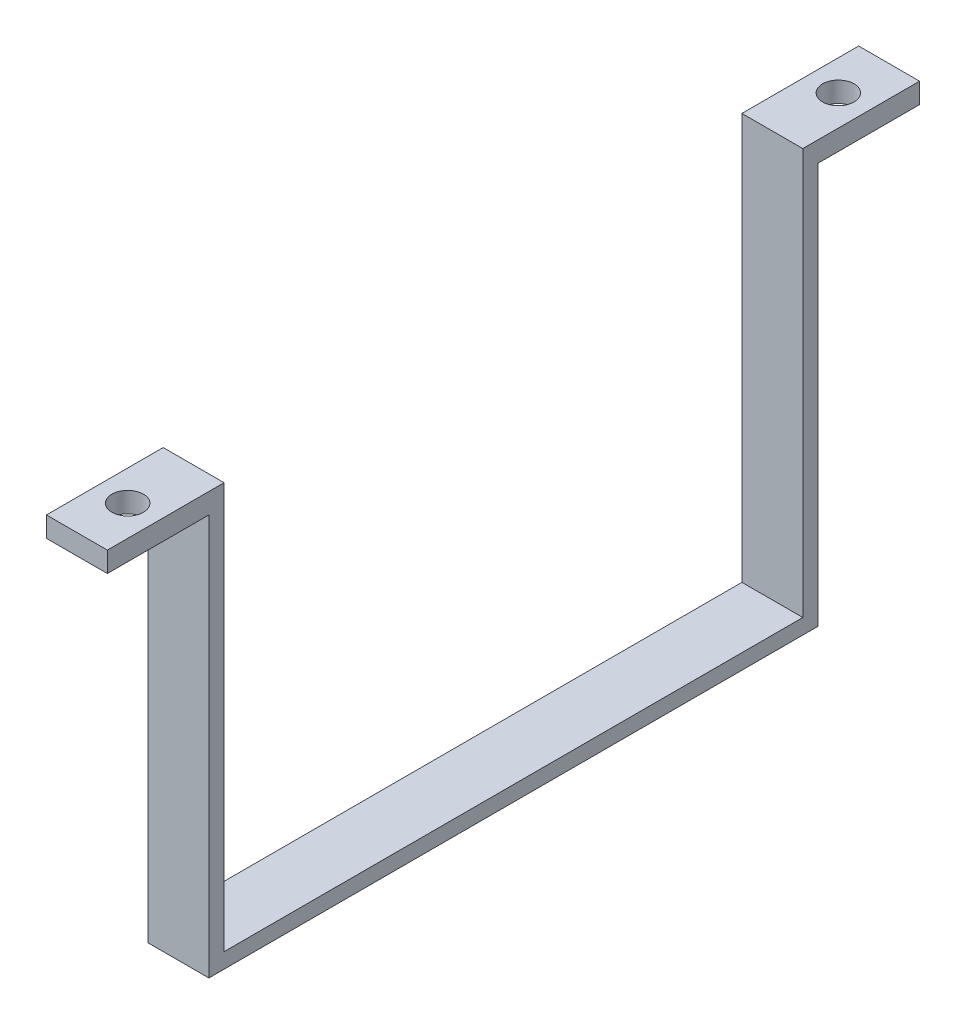
from build123d import *

# Parameters (mm, degrees)
SKETCH1_W           = 50
SKETCH1_H           = 60
SKETCH1_W_2         = 47
SKETCH1_H_2         = 57
BOSS_EXTRUDE6_DEPTH = 40
SKETCH7_W           = 50
SKETCH7_H           = 60
BOSS_EXTRUDE8_DEPTH = 1.5
SKETCH8_W           = 10
SKETCH8_H           = 2
BOSS_EXTRUDE9_DEPTH = 50
SKETCH9_R           = 1.55
CUT_EXTRUDE1_DEPTH  = 3
SKETCH11_R          = 8.25
CUT_EXTRUDE3_DEPTH  = 1.5
SKETCH12_W          = 80
SKETCH12_H          = 42.428758989
CUT_EXTRUDE4_DEPTH  = 2
SKETCH13_W          = 92.772924303
SKETCH13_H          = 57.399075468
CUT_EXTRUDE5_DEPTH  = 42


with BuildPart() as part:
    # Sketch1 → Boss-Extrude6 (new body)
    with BuildSketch(Plane(origin=(0, 0, 0), x_dir=(1, 0, 0), z_dir=(0, 1, 0))):
        Rectangle(SKETCH1_W, SKETCH1_H)
        Rectangle(SKETCH1_W_2, SKETCH1_H_2, mode=Mode.SUBTRACT)
    extrude(amount=BOSS_EXTRUDE6_DEPTH)

    # Sketch7 → Boss-Extrude8 (add)
    with BuildSketch(Plane.XZ):
        Rectangle(SKETCH7_W, SKETCH7_H)
    extrude(amount=BOSS_EXTRUDE8_DEPTH)

    # Sketch8 → Boss-Extrude9 (add)
    with BuildSketch(Plane(origin=(25, 0, 0), x_dir=(0, 0, -1), z_dir=(1, 0, 0))):
        with Locations((-35, 39)):
            Rectangle(SKETCH8_W, SKETCH8_H)
        with Locations((35, 39)):
            Rectangle(SKETCH8_W, SKETCH8_H)
    extrude(amount=-BOSS_EXTRUDE9_DEPTH)

    # Sketch9 → Cut-Extrude1 (cut)
    with BuildSketch(Plane(origin=(0, 40, 0), x_dir=(1, 0, 0), z_dir=(0, 1, 0))):
        with Locations((-20, 35)):
            Circle(SKETCH9_R)
        with Locations((20, 35)):
            Circle(SKETCH9_R)
        with Locations((20, -35)):
            Circle(SKETCH9_R)
        with Locations((-20, -35)):
            Circle(SKETCH9_R)
    extrude(amount=-CUT_EXTRUDE1_DEPTH, mode=Mode.SUBTRACT)

    # Sketch11 → Cut-Extrude3 (cut)
    with BuildSketch(Plane.ZY.offset(25)):
        with Locations((0, 18.25)):
            Circle(SKETCH11_R)
    extrude(amount=-CUT_EXTRUDE3_DEPTH, mode=Mode.SUBTRACT)

    # Sketch12 → Cut-Extrude4 (cut)
    with BuildSketch(Plane.ZY.offset(25)):
        with Locations((0, 18.785620505)):
            Rectangle(SKETCH12_W, SKETCH12_H)
    extrude(amount=-CUT_EXTRUDE4_DEPTH, mode=Mode.SUBTRACT)

    # Sketch13 → Cut-Extrude5 (cut)
    with BuildSketch(Plane(origin=(25, 0, 0), x_dir=(0, 0, -1), z_dir=(1, 0, 0))):
        with Locations((0.049381319, 17.016100398)):
            Rectangle(SKETCH13_W, SKETCH13_H)
    extrude(amount=-CUT_EXTRUDE5_DEPTH, mode=Mode.SUBTRACT)


solid = part.part
